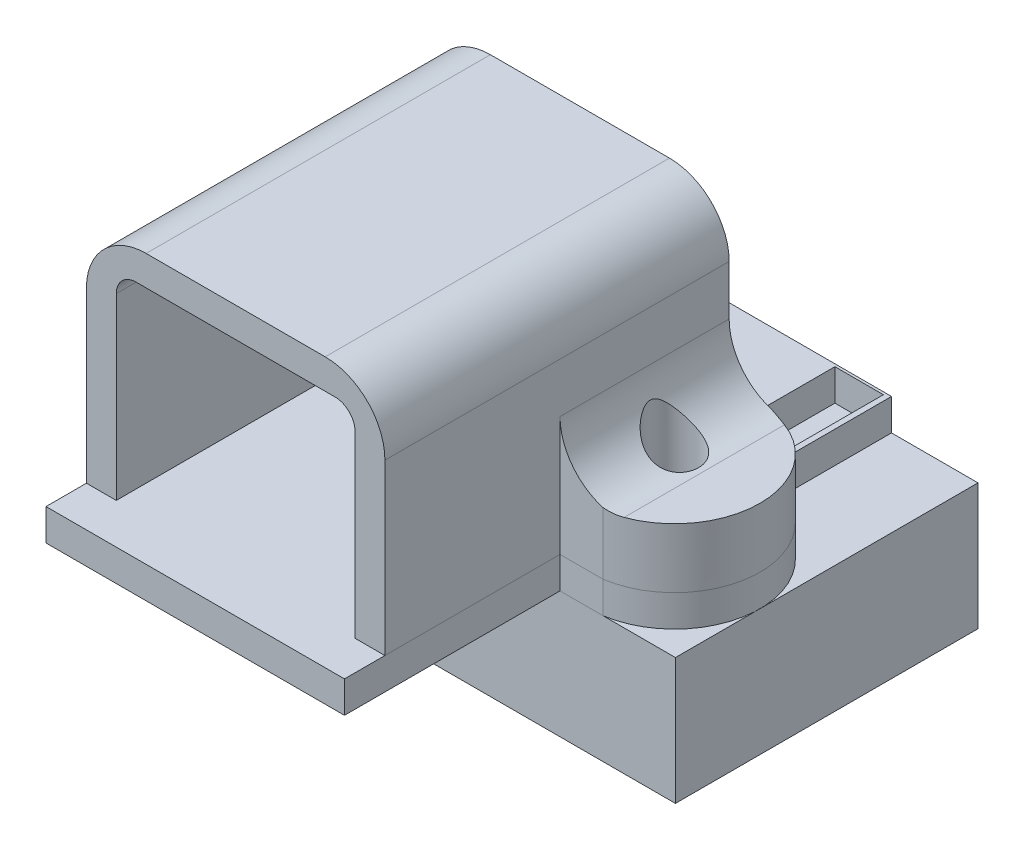
from build123d import *

# Parameters (mm, degrees)
EXTRUDE1_DEPTH            = 17.3
SKETCH2_W                 = 5.8
SKETCH2_H                 = 8.5
EXTRUDE2_DEPTH            = 8.8
SKETCH3_R                 = 1
EXTRUDE3_DEPTH            = 5
F_2_CLEARANCE_HOLE1_D     = 2.4384
F_2_CLEARANCE_HOLE1_DEPTH = 11.5
SKETCH5_R                 = 1.2192
SKETCH5_W                 = 2.4384
SKETCH5_H                 = 5.08
EXTRUDE4_DEPTH            = 1.5875
SKETCH6_W                 = 2.4384
SKETCH6_H                 = 5.08
EXTRUDE5_DEPTH            = 1.27
EXTRUDE5_2_DEPTH          = 1.27
SKETCH7_R                 = 0.381
EXTRUDE6_DEPTH            = 8.128
EXTRUDE6_2_DEPTH          = 8.128
EXTRUDE6_3_DEPTH          = 8.128
EXTRUDE6_4_DEPTH          = 8.128
SKETCH8_R                 = 1.2192
EXTRUDE7_DEPTH            = 6.35


with BuildPart() as part:
    # Sketch1 → Extrude1 (new body)
    with BuildSketch(Plane.XY):
        with BuildLine():
            Line((-13.3, 0), (-6, 0))
            Line((-6, 0), (-6, 9))
            ThreePointArc((-6, 9), (-5.707106781, 9.707106781), (-5, 10))
            Line((-5, 10), (5, 10))
            ThreePointArc((5, 10), (5.707106781, 9.707106781), (6, 9))
            Line((6, 9), (6, 0))
            Line((6, 0), (13.3, 0))
            Line((13.3, 0), (13.3, 3))
            Line((13.3, 3), (10.5, 3))
            ThreePointArc((10.5, 3), (8.378679656, 3.878679656), (7.5, 6))
            Line((7.5, 6), (7.5, 8.5))
            ThreePointArc((7.5, 8.5), (6.621320344, 10.621320344), (4.5, 11.5))
            Line((4.5, 11.5), (-4.5, 11.5))
            ThreePointArc((-4.5, 11.5), (-6.621320344, 10.621320344), (-7.5, 8.5))
            Line((-7.5, 8.5), (-7.5, 6))
            ThreePointArc((-7.5, 6), (-8.378679656, 3.878679656), (-10.5, 3))
            Line((-10.5, 3), (-13.3, 3))
            Line((-13.3, 3), (-13.3, 0))
        make_face()
    extrude(amount=EXTRUDE1_DEPTH)

    # Sketch2 → Extrude2 (cut)
    with BuildSketch(Plane.XY.offset(17.3)):
        with Locations((-10.4, 4.25)):
            Rectangle(SKETCH2_W, SKETCH2_H)
        with Locations((10.4, 4.25)):
            Rectangle(SKETCH2_W, SKETCH2_H)
    extrude(amount=-EXTRUDE2_DEPTH, mode=Mode.SUBTRACT)

    # Sketch3 → Extrude3 (cut)
    with BuildSketch(Plane.XZ):
        with Locations(Location((-9, 4.25, 0), (0, 0, 270))):  # turned: the seam where the file's is
            Circle(SKETCH3_R)
        with Locations(Location((9, 4.25, 0), (0, 0, 270))):  # turned: the seam where the file's is
            Circle(SKETCH3_R)
        with BuildLine():
            Line((9.653834842, 8.5), (9.653834842, 9.262963398))
            Line((9.653834842, 9.262963398), (15.079268599, 9.262963398))
            Line((15.079268599, 9.262963398), (15.079268599, -0.486230121))
            Line((15.079268599, -0.486230121), (9.653834842, -0.486230121))
            Line((9.653834842, -0.486230121), (9.653834842, 0))
            ThreePointArc((9.653834842, 0), (13.3, 4.25), (9.653834842, 8.5))
        make_face()
        with BuildLine():
            Line((-9.653834842, -0.486230121), (-9.653834842, 0))
            ThreePointArc((-9.653834842, 0), (-13.3, 4.25), (-9.653834842, 8.5))
            Line((-9.653834842, 8.5), (-9.653834842, 9.262963398))
            Line((-9.653834842, 9.262963398), (-15.079268599, 9.262963398))
            Line((-15.079268599, 9.262963398), (-15.079268599, -0.486230121))
            Line((-15.079268599, -0.486230121), (-9.653834842, -0.486230121))
        make_face()
    extrude(amount=-EXTRUDE3_DEPTH, mode=Mode.SUBTRACT)

    # #2 Clearance Hole1
    with Locations(Plane(origin=(-9, 0, 4.25), x_dir=(0, 0, -1), z_dir=(0, -1, 0))):
        with Locations((0, 0), (0, 18)):
            Hole(F_2_CLEARANCE_HOLE1_D / 2, depth=F_2_CLEARANCE_HOLE1_DEPTH)


with BuildPart() as body_2:
    # Sketch5 → Extrude4 (new body)
    with BuildSketch(Plane.XZ):
        with BuildLine():
            Line((-8.9535, -6.7056), (-8.9535, 0))
            Line((-8.9535, 0), (-9.653834842, 0))
            ThreePointArc((-9.653834842, 0), (-13.3, 4.25), (-9.653834842, 8.5))
            Line((-9.653834842, 8.5), (-7.5, 8.5))
            Line((-7.5, 8.5), (-7.5, 19.332))
            Line((-7.5, 19.332), (7.5, 19.332))
            Line((7.5, 19.332), (7.5, 8.5))
            Line((7.5, 8.5), (9.653834842, 8.5))
            ThreePointArc((9.653834842, 8.5), (13.3, 4.25), (9.653834842, 0))
            Line((9.653834842, 0), (8.9535, 0))
            Line((8.9535, 0), (8.9535, -6.7056))
            Line((8.9535, -6.7056), (-8.9535, -6.7056))
        make_face()
        with Locations((9, 4.25)):
            Circle(SKETCH5_R, mode=Mode.SUBTRACT)
        with Locations((-9, 4.25)):
            Circle(SKETCH5_R, mode=Mode.SUBTRACT)
        with Locations((-7.4549, -4.0386)):
            Rectangle(SKETCH5_W, SKETCH5_H, mode=Mode.SUBTRACT)
        with Locations((7.4549, -4.0386)):
            Rectangle(SKETCH5_W, SKETCH5_H, mode=Mode.SUBTRACT)
    extrude(amount=EXTRUDE4_DEPTH)


with BuildPart() as body_3:
    # Sketch6 → Extrude5 (new body)
    with BuildSketch(Plane.XZ.offset(1.5875)):
        with Locations((7.4549, -4.0386)):
            Rectangle(SKETCH6_W, SKETCH6_H)
    extrude(amount=EXTRUDE5_DEPTH)


with BuildPart() as body_4:
    # Sketch6 → Extrude5 2 (new body)
    with BuildSketch(Plane.XZ.offset(1.5875)):
        with Locations((-7.4549, -4.0386)):
            Rectangle(SKETCH6_W, SKETCH6_H)
    extrude(amount=EXTRUDE5_2_DEPTH)


with BuildPart() as body_5:
    # Sketch7 → Extrude6 (new body)
    with BuildSketch(Plane.XZ.offset(2.8575)):
        with Locations((-7.4549, -2.425360111)):
            Circle(SKETCH7_R)
    extrude(amount=EXTRUDE6_DEPTH)


with BuildPart() as body_6:
    # Sketch7 → Extrude6 2 (new body)
    with BuildSketch(Plane.XZ.offset(2.8575)):
        with Locations((-7.4549, -5.733691209)):
            Circle(SKETCH7_R)
    extrude(amount=EXTRUDE6_2_DEPTH)


with BuildPart() as body_7:
    # Sketch7 → Extrude6 3 (new body)
    with BuildSketch(Plane.XZ.offset(2.8575)):
        with Locations(Location((7.4549, -5.733691209, 0), (0, 0, 180))):  # turned: the seam where the file's is
            Circle(SKETCH7_R)
    extrude(amount=EXTRUDE6_3_DEPTH)


with BuildPart() as body_8:
    # Sketch7 → Extrude6 4 (new body)
    with BuildSketch(Plane.XZ.offset(2.8575)):
        with Locations(Location((7.4549, -2.425360111, 0), (0, 0, 180))):  # turned: the seam where the file's is
            Circle(SKETCH7_R)
    extrude(amount=EXTRUDE6_4_DEPTH)


with BuildPart() as body_9:
    # Sketch8 → Extrude7 (new body)
    with BuildSketch(Plane.XZ.offset(1.5875)):
        Polygon((-13.3, 8.5), (13.3, 8.5), (13.3, -6.7056), (8.808846723, -6.7056), (8.808846723, -1.308184758), (6.080310838, -1.308184758), (6.080310838, -6.7056), (-6.080310838, -6.7056), (-6.080310838, -1.308184758), (-8.808846723, -1.308184758), (-8.808846723, -6.7056), (-13.3, -6.7056), align=None)
        with Locations((-9, 4.25)):
            Circle(SKETCH8_R, mode=Mode.SUBTRACT)
        with Locations((9, 4.25)):
            Circle(SKETCH8_R, mode=Mode.SUBTRACT)
    extrude(amount=EXTRUDE7_DEPTH)


solid = Compound([part.part, body_2.part, body_3.part, body_4.part, body_5.part, body_6.part, body_7.part, body_8.part, body_9.part])
